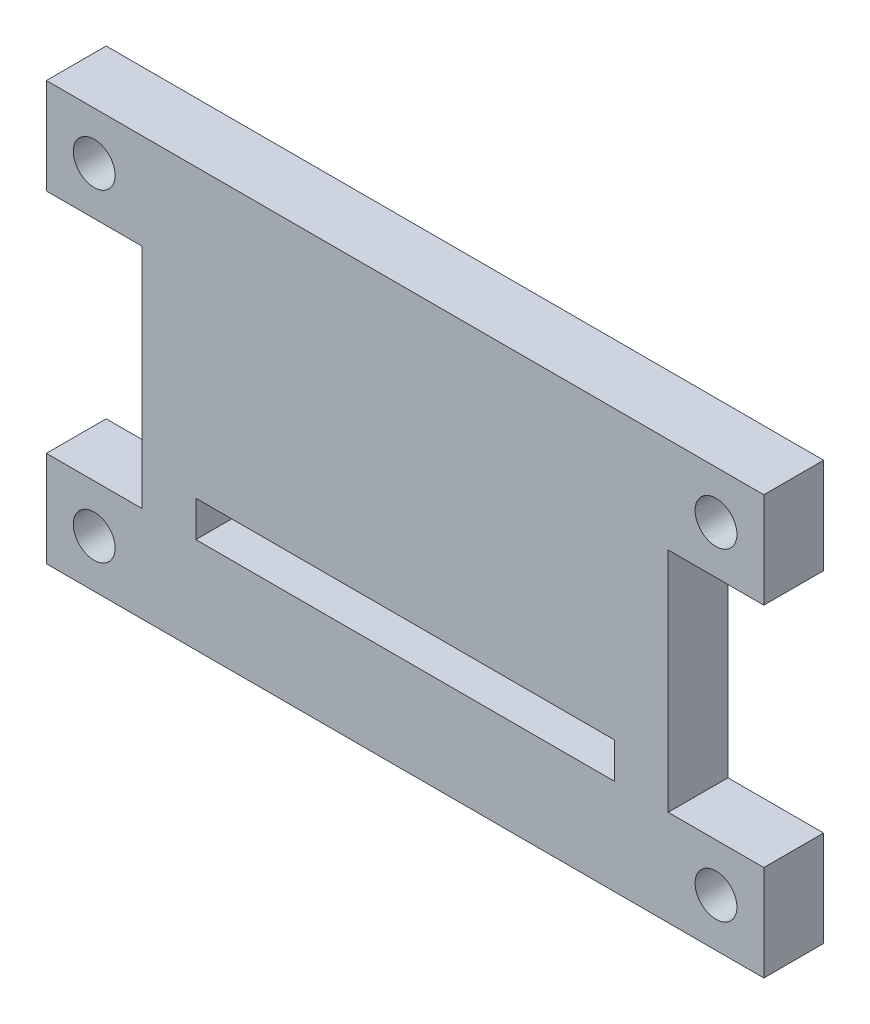
from build123d import *

# Parameters (mm, degrees)
SKETCH_1_R          = 1.75
EXTRUDE_1_DEPTH     = 5
CUT_EXTRUDE_1_REACH = 7
SKETCH_2_W          = 35
SKETCH_2_H          = 3


with BuildPart() as part:
    # 草圖1 → 填料-伸長1 (new body)
    with BuildSketch(Plane.XY):
        Polygon((-30, 17.5), (-30, 9.5), (-22, 9.5), (-22, -9.5), (-30, -9.5), (-30, -17.5), (30, -17.5), (30, -9.5), (22, -9.5), (22, 9.5), (30, 9.5), (30, 17.5), align=None)
        with Locations((-26, 13.5)):
            Circle(SKETCH_1_R, mode=Mode.SUBTRACT)
        with Locations((26, 13.5)):
            Circle(SKETCH_1_R, mode=Mode.SUBTRACT)
        with Locations((-26, -13.5)):
            Circle(SKETCH_1_R, mode=Mode.SUBTRACT)
        with Locations((26, -13.5)):
            Circle(SKETCH_1_R, mode=Mode.SUBTRACT)
    extrude(amount=EXTRUDE_1_DEPTH)

    # 草圖2 → 除料-伸長1 (cut, up to next)
    with BuildSketch(Plane.XY.offset(5), mode=Mode.PRIVATE) as cut_extrude_1_sk1:
        with Locations((0, -8)):
            Rectangle(SKETCH_2_W, SKETCH_2_H)
    cut_extrude_1_tool1 = extrude(cut_extrude_1_sk1.sketch, amount=-CUT_EXTRUDE_1_REACH, mode=Mode.PRIVATE) & part.part
    add(cut_extrude_1_tool1.solids().sort_by_distance((0, -8, 5))[0], mode=Mode.SUBTRACT)


solid = part.part
